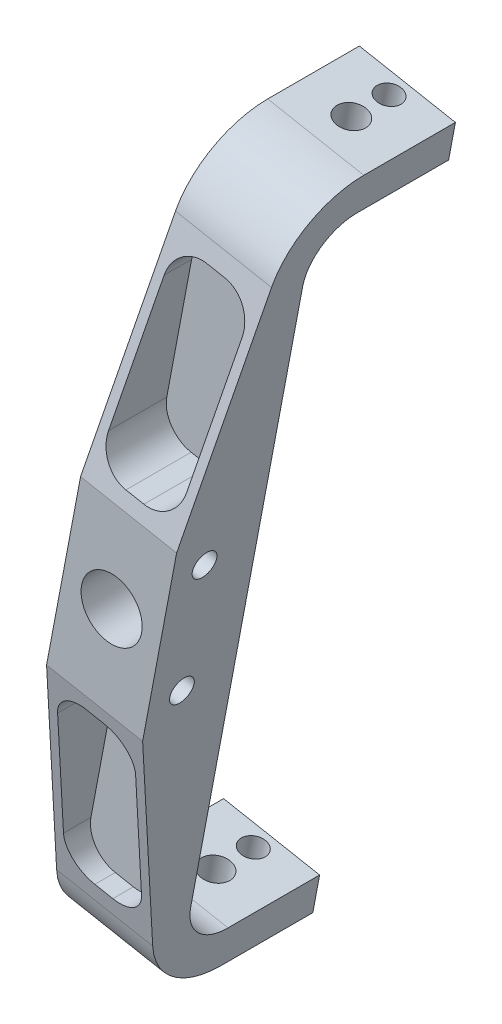
from build123d import *

# Parameters (mm, degrees)
SKETCH1_R               = 10
BOSS_EXTRUDE1_DEPTH     = 28.5
BOSS_EXTRUDE2_DEPTH     = 45
SKETCH4_R               = 4.7625
SKETCH4_R_2             = 3.96875
CUT_EXTRUDE1_DEPTH      = 258.595725096
FILLET3_R               = 15
SKETCH10_R              = 4
CUT_EXTRUDE2_DEPTH      = 78.869968284
CUT_EXTRUDE2_DEPTH_BACK = 46.869968284
CUT_EXTRUDE4_DEPTH      = 22.5


with BuildPart() as part:
    # Sketch1 → Boss-Extrude1 (new body)
    with BuildSketch(Plane.XY):
        Polygon((-7.617068705, -126.66669812), (39.062241625, 120.733646626), (7.617068705, 126.66669812), (-39.062241625, -120.733646626), align=None)
        Circle(SKETCH1_R, mode=Mode.SUBTRACT)
    extrude(amount=BOSS_EXTRUDE1_DEPTH)

    # Sketch2 → Boss-Extrude2 (add)
    with BuildSketch(Plane(origin=(0, 0, 0), x_dir=(-1, 0, 0), z_dir=(0, 0, -1))):
        Polygon((-39.062241625, 120.733646626), (-36.837347314, 108.941706781), (-5.392174394, 114.874758275), (-7.617068705, 126.66669812), align=None)
        Polygon((36.837347314, -108.941706781), (5.392174394, -114.874758275), (7.617068705, -126.66669812), (39.062241625, -120.733646626), align=None)
    extrude(amount=BOSS_EXTRUDE2_DEPTH)

    # Sketch4 → Cut-Extrude1 (cut, through all)
    with BuildSketch(Plane(origin=(-1.656161502, 128.416364197, 0), x_dir=(0.982661654, -0.185407859, 0), z_dir=(0.185407859, 0.982661654, 0))):
        with Locations((25.436849572, 26.64759704)):
            Circle(SKETCH4_R)
        with Locations((25.436849572, 39)):
            Circle(SKETCH4_R_2)
    extrude(amount=-CUT_EXTRUDE1_DEPTH, mode=Mode.SUBTRACT)

    # Fillet3
    fillet3_edges = [part.edges().sort_by_distance(p)[0] for p in [
        (21.114760854, 111.908232528, 0),
        (-21.114760854, -111.908232528, 0),
    ]]
    fillet(fillet3_edges, radius=FILLET3_R)

    # Sketch10 → Cut-Extrude2 (cut, two sides)
    with BuildSketch(Plane(origin=(-16.024269994, 1.367603019, 0), x_dir=(0, 0, -1), z_dir=(0.982661654, -0.185407859, 0))) as cut_extrude2_sk:
        with Locations((-17.5, 21.627134551)):
            Circle(SKETCH10_R)
        with Locations((-17.5, -18.372865449)):
            Circle(SKETCH10_R)
        with BuildLine():
            Line((-28.5, 31.627134551), (-11.316666773, 106.545885621))
            ThreePointArc((-11.316666773, 106.545885621), (-1.82302812, 121.628280107), (15, 127.509906002))
            Line((15, 127.509906002), (-43.528341994, 140.350199542))
            Line((-43.528341994, 140.350199542), (-46.913882941, 31.627134551))
            Line((-46.913882941, 31.627134551), (-28.5, 31.627134551))
        make_face()
        with BuildLine():
            Line((-43.528341994, -137.095930441), (15, -124.255636901))
            ThreePointArc((15, -124.255636901), (-1.82302812, -118.374011006), (-11.316666773, -103.29161652))
            Line((-11.316666773, -103.29161652), (-28.5, -28.372865449))
            Line((-28.5, -28.372865449), (-46.913882941, -28.372865449))
            Line((-46.913882941, -28.372865449), (-43.528341994, -137.095930441))
        make_face()
    extrude(amount=CUT_EXTRUDE2_DEPTH, mode=Mode.SUBTRACT)
    extrude(cut_extrude2_sk.sketch, amount=-CUT_EXTRUDE2_DEPTH_BACK, mode=Mode.SUBTRACT)

    # Sketch11 → Cut-Extrude4 (cut)
    with BuildSketch(Plane.XY.offset(28.5)):
        with BuildLine():
            Line((3.541290111, 34.949381459), (9.437260033, 33.836934304))
            ThreePointArc((9.437260033, 33.836934304), (16.92877427, 35.404052106), (21.117955163, 41.809472249))
            Line((21.117955163, 41.809472249), (29.254165873, 84.931389014))
            ThreePointArc((29.254165873, 84.931389014), (27.687048071, 92.422903251), (21.281627928, 96.612084144))
            Line((21.281627928, 96.612084144), (15.385658005, 97.724531299))
            ThreePointArc((15.385658005, 97.724531299), (7.894143769, 96.157413497), (3.704962876, 89.751993354))
            Line((3.704962876, 89.751993354), (-4.431247835, 46.630076588))
            ThreePointArc((-4.431247835, 46.630076588), (-2.864130032, 39.138562352), (3.541290111, 34.949381459))
        make_face()
        with BuildLine():
            Line((-21.281627928, -96.612084144), (-15.385658005, -97.724531299))
            ThreePointArc((-15.385658005, -97.724531299), (-7.894143769, -96.157413497), (-3.704962876, -89.751993354))
            Line((-3.704962876, -89.751993354), (4.431247835, -46.630076588))
            ThreePointArc((4.431247835, -46.630076588), (2.864130032, -39.138562352), (-3.541290111, -34.949381459))
            Line((-3.541290111, -34.949381459), (-9.437260033, -33.836934304))
            ThreePointArc((-9.437260033, -33.836934304), (-16.92877427, -35.404052106), (-21.117955163, -41.809472249))
            Line((-21.117955163, -41.809472249), (-29.254165873, -84.931389014))
            ThreePointArc((-29.254165873, -84.931389014), (-27.687048071, -92.422903251), (-21.281627928, -96.612084144))
        make_face()
    extrude(amount=-CUT_EXTRUDE4_DEPTH, mode=Mode.SUBTRACT)


solid = part.part
